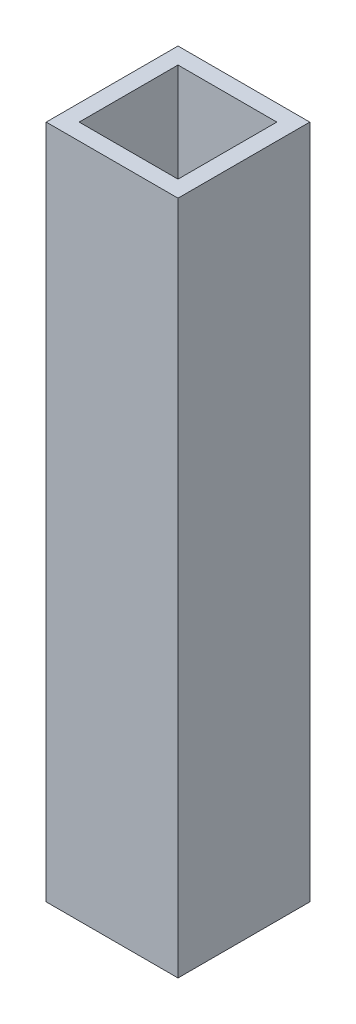
from build123d import *

# Parameters (mm, degrees)
SKETCH3_W           = 40
SKETCH3_H           = 40
SKETCH3_W_2         = 30
SKETCH3_H_2         = 30
BOSS_EXTRUDE1_DEPTH = 205


with BuildPart() as part:
    # Sketch3 → Boss-Extrude1 (new body)
    with BuildSketch(Plane(origin=(0, 0, 0), x_dir=(1, 0, 0), z_dir=(0, 1, 0))):
        Rectangle(SKETCH3_W, SKETCH3_H)
        Rectangle(SKETCH3_W_2, SKETCH3_H_2, mode=Mode.SUBTRACT)
    extrude(amount=BOSS_EXTRUDE1_DEPTH)


solid = part.part
